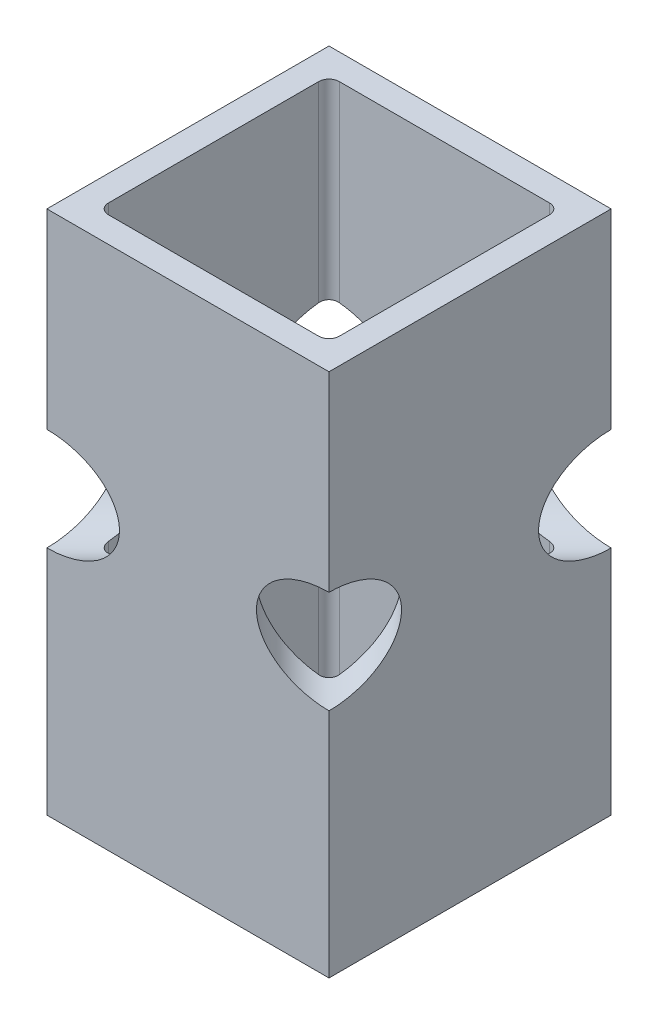
from build123d import *

# Parameters (mm, degrees)
SKETCH1_W               = 34.925
SKETCH1_H               = 34.925
SKETCH1_W_2             = 28.575
SKETCH1_H_2             = 28.575
BOSS_EXTRUDE1_DEPTH     = 65
FILLET1_R               = 1.27
SKETCH2_R               = 6.35
CUT_EXTRUDE1_DEPTH      = 25.695704333
CUT_EXTRUDE1_DEPTH_BACK = 25.695704333
SKETCH3_R               = 6.35
CUT_EXTRUDE2_DEPTH      = 25.695704474
CUT_EXTRUDE2_DEPTH_BACK = 25.695704474


with BuildPart() as part:
    # Sketch1 → Boss-Extrude1 (new body)
    with BuildSketch(Plane(origin=(0, 0, 0), x_dir=(1, 0, 0), z_dir=(0, 1, 0))):
        Rectangle(SKETCH1_W, SKETCH1_H)
        Rectangle(SKETCH1_W_2, SKETCH1_H_2, mode=Mode.SUBTRACT)
    extrude(amount=BOSS_EXTRUDE1_DEPTH)

    # Fillet1
    fillet1_edges = [part.edges().sort_by_distance(p)[0] for p in [
        (-14.2875, 32.5, 14.2875),
        (14.2875, 32.5, 14.2875),
        (14.2875, 32.5, -14.2875),
        (-14.2875, 32.5, -14.2875),
    ]]
    fillet(fillet1_edges, radius=FILLET1_R)

    # Sketch2 → Cut-Extrude1 (cut, two sides)
    with BuildSketch(Plane(origin=(0, 0, 0), x_dir=(0.707106781, 0, 0.707106781), z_dir=(-0.707106781, 0, 0.707106781))) as cut_extrude1_sk:
        with Locations((0, 35)):
            Circle(SKETCH2_R)
    extrude(amount=CUT_EXTRUDE1_DEPTH, mode=Mode.SUBTRACT)
    extrude(cut_extrude1_sk.sketch, amount=-CUT_EXTRUDE1_DEPTH_BACK, mode=Mode.SUBTRACT)

    # Sketch3 → Cut-Extrude2 (cut, two sides)
    with BuildSketch(Plane(origin=(0, 0, 0), x_dir=(0.707106781, 0, -0.707106781), z_dir=(0.707106781, 0, 0.707106781))) as cut_extrude2_sk:
        with Locations((0, 35)):
            Circle(SKETCH3_R)
    extrude(amount=CUT_EXTRUDE2_DEPTH, mode=Mode.SUBTRACT)
    extrude(cut_extrude2_sk.sketch, amount=-CUT_EXTRUDE2_DEPTH_BACK, mode=Mode.SUBTRACT)


solid = part.part
